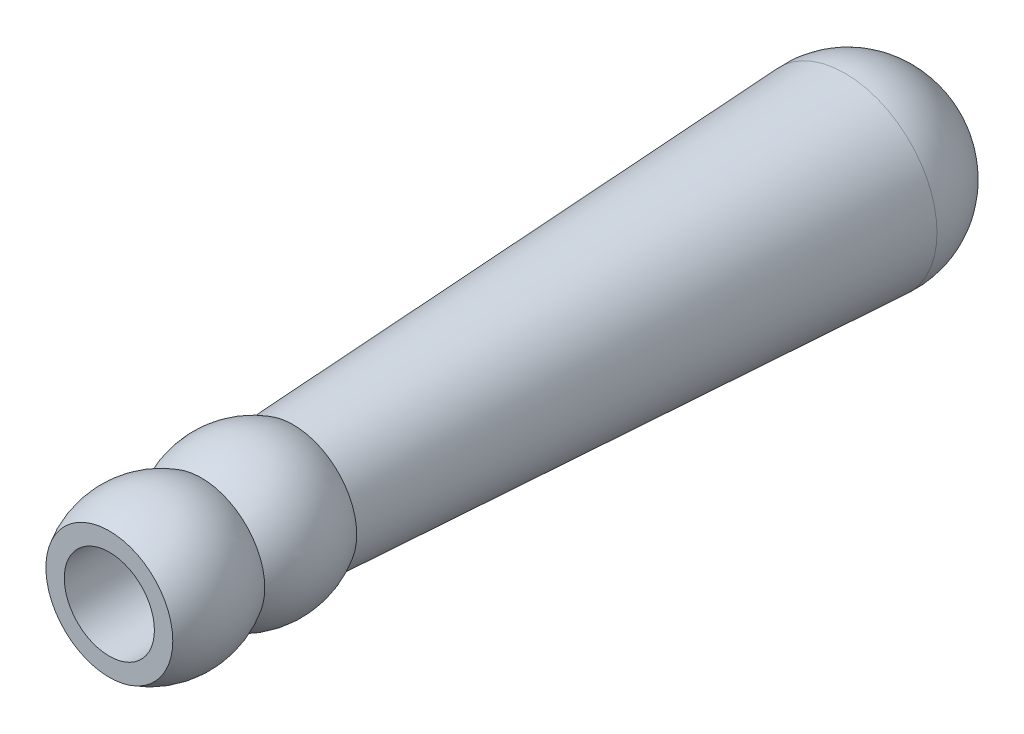
from build123d import *


with BuildPart() as part:
    # Sketch1 → Revolve1 (revolve)
    with BuildSketch(Plane(origin=(0, 0, 0), x_dir=(1, 0, 0), z_dir=(0, 1, 0))):
        with BuildLine():
            Line((8.763, 25.4), (12.7, 101.6))
            ThreePointArc((12.7, 101.6), (9.191372869, 110.791372869), (0, 114.3))
            Line((0, 114.3), (0, 19.05))
            Line((0, 19.05), (6.223, 19.05))
            Line((6.223, 19.05), (6.223, 0))
            Line((6.223, 0), (8.763, 0))
            ThreePointArc((8.763, 0), (10.532289915, 6.35), (8.763, 12.7))
            ThreePointArc((8.763, 12.7), (10.532289915, 19.05), (8.763, 25.4))
        make_face()
    revolve(axis=Axis((0, 0, 810.661063807), (0, 0, -1)))


solid = part.part
